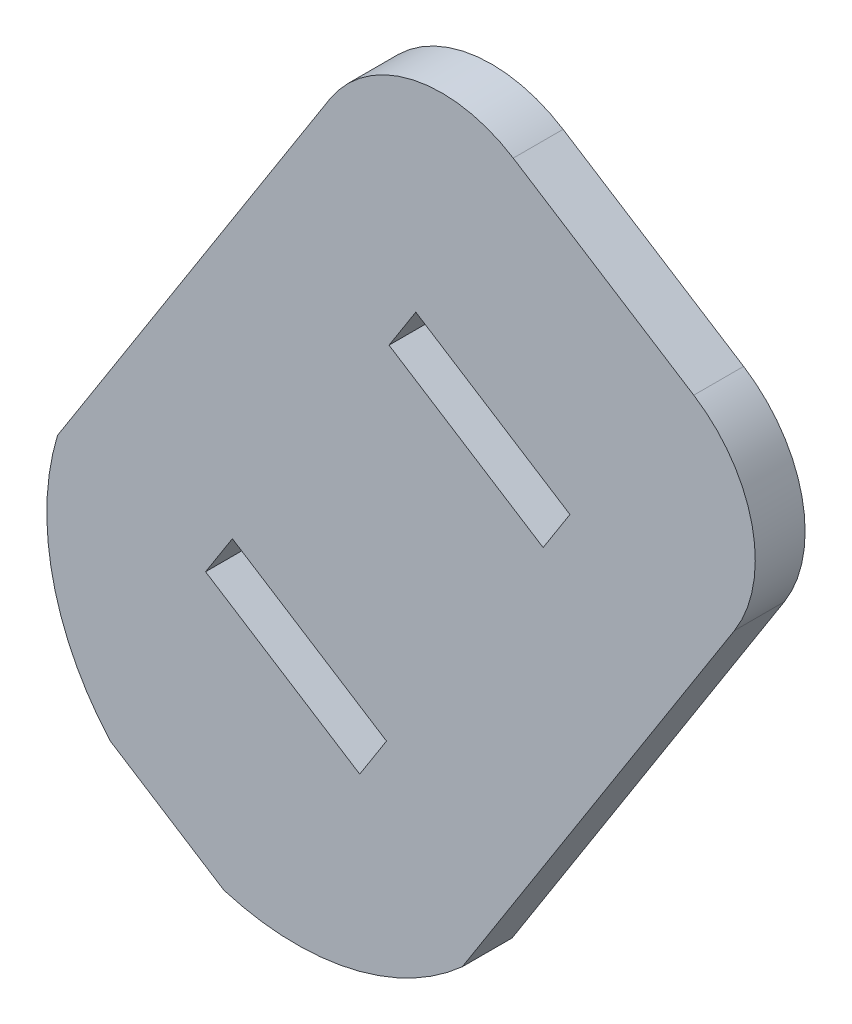
from build123d import *

# Parameters (mm, degrees)
CROQUIS1_R                 = 8
SALIENTE_EXTRUIR1_DEPTH    = 8
SALIENTE_EXTRUIR2_DEPTH    = 3
CORTAR_EXTRUIR1_DEPTH      = 10
CORTAR_EXTRUIR1_DEPTH_BACK = 10


with BuildPart() as part:
    # Croquis1 → Saliente-Extruir1 (new body)
    with BuildSketch(Plane.XY):
        with Locations((-35.87588422, 30.387347076)):
            Circle(CROQUIS1_R)
    extrude(amount=-SALIENTE_EXTRUIR1_DEPTH)

    # Croquis2 → Saliente-Extruir2 (add)
    with BuildSketch(Plane.XY):
        with BuildLine():
            Line((-33.848986828, 60.448524076), (-45.879424714, 41.56451924))
            Line((-45.879424714, 41.56451924), (-50.233521284, 34.729956653))
            ThreePointArc((-50.233521284, 34.729956653), (-50.520324327, 27.140752867), (-47.053056384, 20.383806582))
            Line((-47.053056384, 20.383806582), (-40.218493797, 16.029710012))
            ThreePointArc((-40.218493797, 16.029710012), (-32.629290011, 15.74290697), (-25.872343726, 19.210174912))
            Line((-25.872343726, 19.210174912), (-21.518247156, 26.044737499))
            Line((-21.518247156, 26.044737499), (-9.48780927, 44.928742335))
            ThreePointArc((-9.48780927, 44.928742335), (-8.42457278, 50.958656113), (-11.93654397, 55.974270768))
            Line((-11.93654397, 55.974270768), (-13.952719889, 57.258716487))
            Line((-13.952719889, 57.258716487), (-20.787282476, 61.612813057))
            Line((-20.787282476, 61.612813057), (-22.803458395, 62.897258775))
            ThreePointArc((-22.803458395, 62.897258775), (-28.833372173, 63.960495266), (-33.848986828, 60.448524076))
        make_face()
    extrude(amount=SALIENTE_EXTRUIR2_DEPTH)

    # Croquis5 → Cortar-Extruir1 (cut, two sides)
    with BuildSketch(Plane.XY) as cortar_extruir1_sk:
        Polygon((-19.390525704, 46.02780209), (-21.002424529, 43.497627753), (-30.279730433, 49.407923445), (-28.667831608, 51.938097782), align=None)
        Polygon((-30.431281855, 28.697286399), (-32.04318068, 26.167112062), (-41.320486584, 32.077407754), (-39.708587759, 34.607582091), align=None)
    extrude(amount=CORTAR_EXTRUIR1_DEPTH, mode=Mode.SUBTRACT)
    extrude(cortar_extruir1_sk.sketch, amount=-CORTAR_EXTRUIR1_DEPTH_BACK, mode=Mode.SUBTRACT)


solid = part.part
